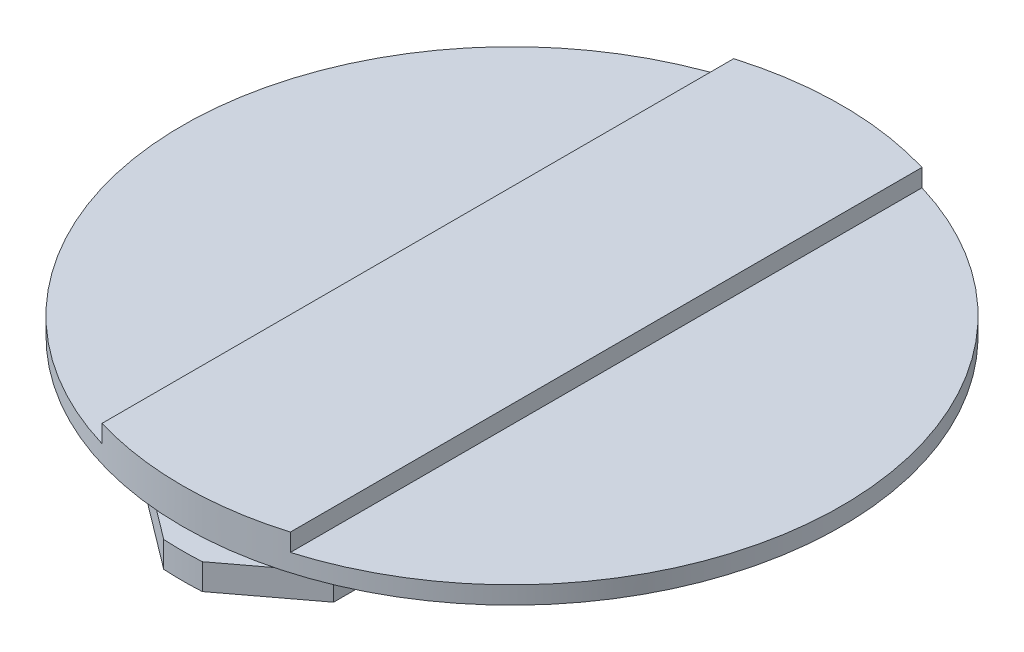
from build123d import *

# Parameters (mm, degrees)
SKETCH_2_W               = 20
SKETCH_2_H               = 1.5
SKETCH_2_H_2             = 2.45
CUT_EXTRUDE_1_DEPTH      = 29
CUT_EXTRUDE_1_DEPTH_BACK = 29
CUT_EXTRUDE_2_DEPTH      = 2.45


with BuildPart() as part:
    # Эскиз1 → Повернуть1 (revolve)
    with BuildSketch(Plane.XY):
        Polygon((0, 0), (0, 7), (28, 7), (28, 4), (24.5, 4), (24.5, 2.2), (28, 2.2), (28, 0), align=None)
    revolve(axis=Axis((0, 16.311603896, 0), (0, -1, 0)))

    # Эскиз2 → Вырез-Вытянуть1 (cut, two sides)
    with BuildSketch(Plane.XY) as cut_extrude_1_sk:
        with Locations((18, 6.25)):
            Rectangle(SKETCH_2_W, SKETCH_2_H)
        with Locations((-18, 6.25)):
            Rectangle(SKETCH_2_W, SKETCH_2_H)
        with Locations((18, 1.225)):
            Rectangle(SKETCH_2_W, SKETCH_2_H_2)
        with Locations((-18, 1.225)):
            Rectangle(SKETCH_2_W, SKETCH_2_H_2)
    extrude(amount=CUT_EXTRUDE_1_DEPTH, mode=Mode.SUBTRACT)
    extrude(cut_extrude_1_sk.sketch, amount=-CUT_EXTRUDE_1_DEPTH_BACK, mode=Mode.SUBTRACT)

    # Эскиз3 → Вырез-Вытянуть2 (cut)
    with BuildSketch(Plane.XZ):
        with BuildLine():
            ThreePointArc((8, 26.83281573), (4.850771024, 27.576620904), (1.636756478, 27.952120281))
            Line((1.636756478, 27.952120281), (8, 23.157072354))
            Line((8, 23.157072354), (8, 26.83281573))
        make_face()
        with BuildLine():
            Line((-8, 26.83281573), (-8, 23.157072354))
            Line((-8, 23.157072354), (-1.636756478, 27.952120281))
            ThreePointArc((-1.636756478, 27.952120281), (-4.850771024, 27.576620904), (-8, 26.83281573))
        make_face()
        with BuildLine():
            Line((-1.636756478, -27.952120281), (-8, -23.157072354))
            Line((-8, -23.157072354), (-8, -26.83281573))
            ThreePointArc((-8, -26.83281573), (-4.850771024, -27.576620904), (-1.636756478, -27.952120281))
        make_face()
        with BuildLine():
            Line((8, -23.157072354), (1.636756478, -27.952120281))
            ThreePointArc((1.636756478, -27.952120281), (4.850771024, -27.576620904), (8, -26.83281573))
            Line((8, -26.83281573), (8, -23.157072354))
        make_face()
    extrude(amount=-CUT_EXTRUDE_2_DEPTH, mode=Mode.SUBTRACT)


solid = part.part
